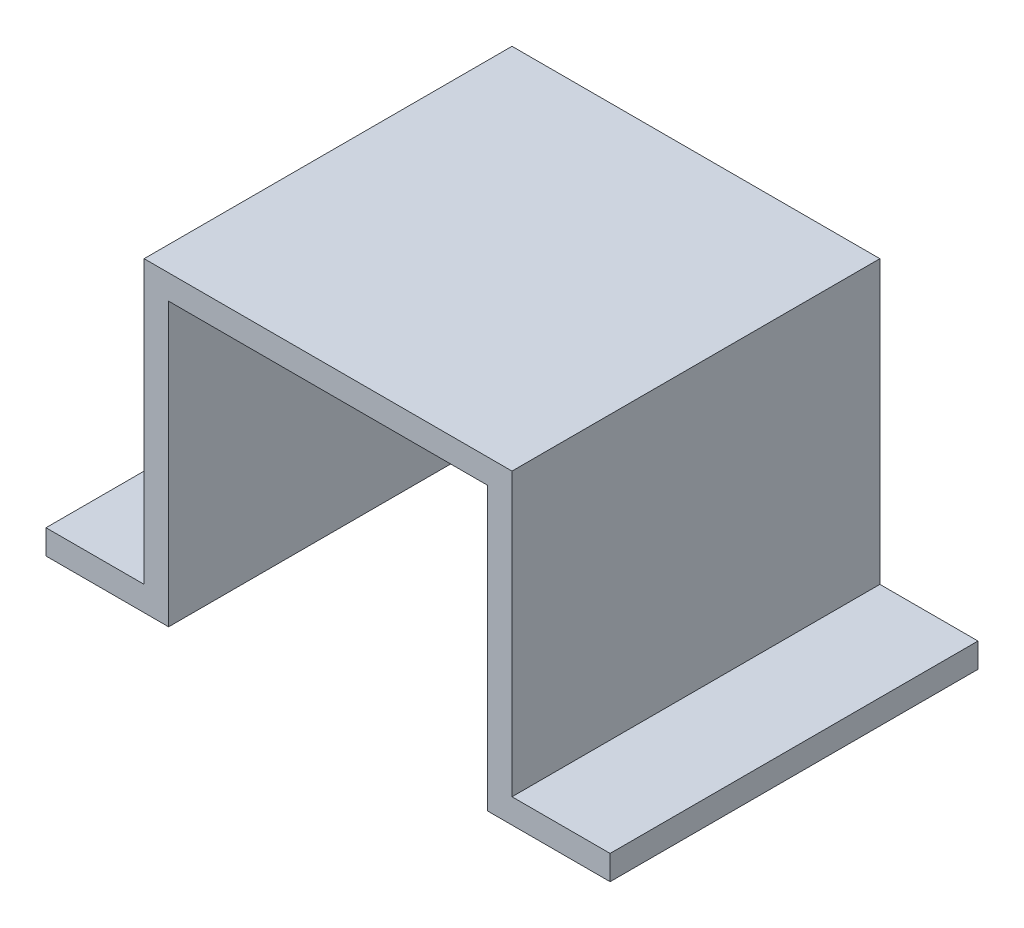
from build123d import *

# Parameters (mm, degrees)
BOSS_EXTRUDE1_DEPTH = 15


with BuildPart() as part:
    # Sketch1 → Boss-Extrude1 (new body, symmetric)
    with BuildSketch(Plane.XY):
        Polygon((0, 0), (10, 0), (10, 23), (36, 23), (36, 0), (46, 0), (46, 2), (38, 2), (38, 25), (8, 25), (8, 2), (0, 2), align=None)
    extrude(amount=BOSS_EXTRUDE1_DEPTH, both=True)


solid = part.part
